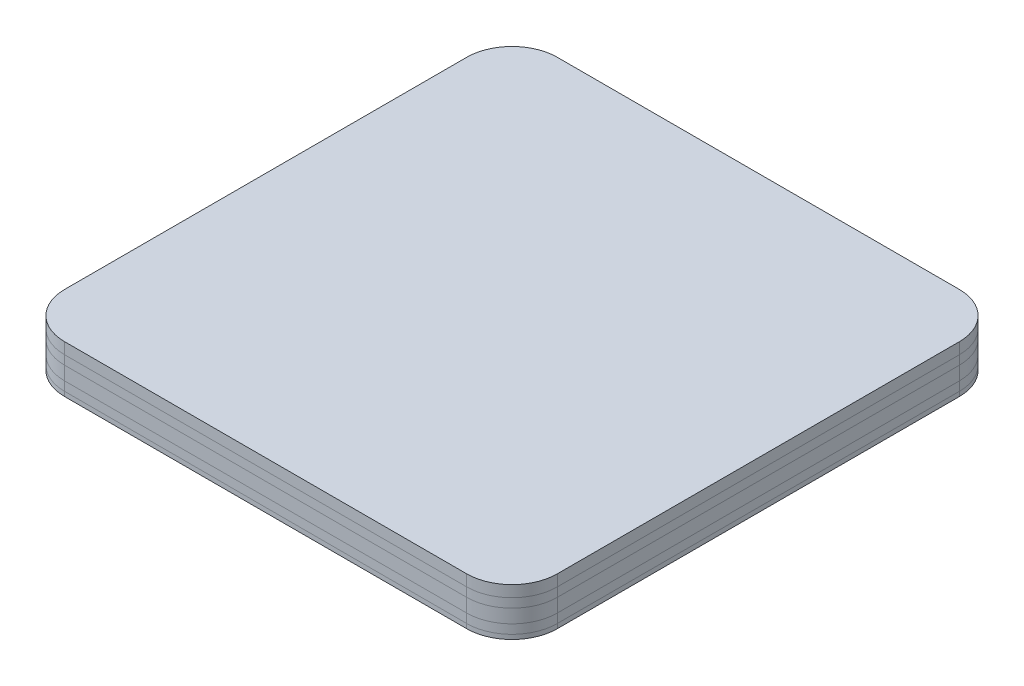
from build123d import *

# Parameters (mm, degrees)
BOSS_EXTRUDE1_DEPTH   = 0.1
BOSS_EXTRUDE2_START   = -0.1
BOSS_EXTRUDE2_DEPTH   = 1
BOSS_EXTRUDE3_DEPTH   = 4
BOSS_EXTRUDE3_2_DEPTH = 4
BOSS_EXTRUDE3_3_DEPTH = 4
BOSS_EXTRUDE3_4_DEPTH = 4
BOSS_EXTRUDE4_DEPTH   = 2
BOSS_EXTRUDE5_START   = 2
BOSS_EXTRUDE5_DEPTH   = 3
BOSS_EXTRUDE6_START   = 5
BOSS_EXTRUDE6_DEPTH   = 2
BOSS_EXTRUDE7_START   = 7
BOSS_EXTRUDE7_DEPTH   = 2.5


with BuildPart() as part:
    # Sketch2 → Boss-Extrude1 (new body)
    with BuildSketch(Plane(origin=(0, 0, 0), x_dir=(1, 0, 0), z_dir=(0, 1, 0))):
        with BuildLine():
            Line((44.4, 52.9), (-44.4, 52.9))
            ThreePointArc((-44.4, 52.9), (-50.41040764, 50.41040764), (-52.9, 44.4))
            Line((-52.9, 44.4), (-52.9, -44.4))
            ThreePointArc((-52.9, -44.4), (-50.41040764, -50.41040764), (-44.4, -52.9))
            Line((-44.4, -52.9), (44.4, -52.9))
            ThreePointArc((44.4, -52.9), (50.41040764, -50.41040764), (52.9, -44.4))
            Line((52.9, -44.4), (52.9, 44.4))
            ThreePointArc((52.9, 44.4), (50.41040764, 50.41040764), (44.4, 52.9))
        make_face()
        with BuildLine():
            Line((44.4, 51.9), (-44.4, 51.9))
            ThreePointArc((-44.4, 51.9), (-49.703300859, 49.703300859), (-51.9, 44.4))
            Line((-51.9, 44.4), (-51.9, -44.4))
            ThreePointArc((-51.9, -44.4), (-49.703300859, -49.703300859), (-44.4, -51.9))
            Line((-44.4, -51.9), (44.4, -51.9))
            ThreePointArc((44.4, -51.9), (49.703300859, -49.703300859), (51.9, -44.4))
            Line((51.9, -44.4), (51.9, 44.4))
            ThreePointArc((51.9, 44.4), (49.703300859, 49.703300859), (44.4, 51.9))
        make_face(mode=Mode.SUBTRACT)
    extrude(amount=-BOSS_EXTRUDE1_DEPTH)

    # Sketch1 → Boss-Extrude2 (add)
    with BuildSketch(Plane(origin=(0, 0, 0), x_dir=(1, 0, 0), z_dir=(0, 1, 0)).offset(BOSS_EXTRUDE2_START)):
        with BuildLine():
            Line((54.4, -44.4), (54.4, 44.4))
            ThreePointArc((54.4, 44.4), (51.471067812, 51.471067812), (44.4, 54.4))
            Line((44.4, 54.4), (-44.4, 54.4))
            ThreePointArc((-44.4, 54.4), (-51.471067812, 51.471067812), (-54.4, 44.4))
            Line((-54.4, 44.4), (-54.4, -44.4))
            ThreePointArc((-54.4, -44.4), (-51.471067812, -51.471067812), (-44.4, -54.4))
            Line((-44.4, -54.4), (44.4, -54.4))
            ThreePointArc((44.4, -54.4), (51.471067812, -51.471067812), (54.4, -44.4))
        make_face()
        with BuildLine():
            ThreePointArc((-44.4, 53.4), (-50.763961031, 50.763961031), (-53.4, 44.4))
            Line((-53.4, 44.4), (-53.4, -44.4))
            ThreePointArc((-53.4, -44.4), (-50.763961031, -50.763961031), (-44.4, -53.4))
            Line((-44.4, -53.4), (44.4, -53.4))
            ThreePointArc((44.4, -53.4), (50.763961031, -50.763961031), (53.4, -44.4))
            Line((53.4, -44.4), (53.4, 44.4))
            ThreePointArc((53.4, 44.4), (50.763961031, 50.763961031), (44.4, 53.4))
            Line((44.4, 53.4), (-44.4, 53.4))
        make_face(mode=Mode.SUBTRACT)
        with BuildLine():
            Line((-44.4, 53.4), (44.4, 53.4))
            ThreePointArc((44.4, 53.4), (50.763961031, 50.763961031), (53.4, 44.4))
            Line((53.4, 44.4), (53.4, -44.4))
            ThreePointArc((53.4, -44.4), (50.763961031, -50.763961031), (44.4, -53.4))
            Line((44.4, -53.4), (-44.4, -53.4))
            ThreePointArc((-44.4, -53.4), (-50.763961031, -50.763961031), (-53.4, -44.4))
            Line((-53.4, -44.4), (-53.4, 44.4))
            ThreePointArc((-53.4, 44.4), (-50.763961031, 50.763961031), (-44.4, 53.4))
        make_face()
    extrude(amount=BOSS_EXTRUDE2_DEPTH)


with BuildPart() as body_2:
    # Sketch3 → Boss-Extrude3 (new body)
    with BuildSketch(Plane.XZ.offset(0.1)):
        Polygon((-41.140539781, 40.026118716), (-37.997071749, 34.468775471), (-31.612537306, 34.41242702), (-28.371470895, 39.913421814), (-31.514938926, 45.470765058), (-37.899473369, 45.527113509), align=None)
    extrude(amount=BOSS_EXTRUDE3_DEPTH)


with BuildPart() as body_3:
    # Sketch3 → Boss-Extrude3 2 (new body)
    with BuildSketch(Plane.XZ.offset(0.1)):
        Polygon((23.419460219, 40.026118716), (26.56292825, 34.468775471), (32.947462693, 34.41242702), (36.188529105, 39.913421814), (33.045061073, 45.470765058), (26.66052663, 45.527113509), align=None)
    extrude(amount=BOSS_EXTRUDE3_2_DEPTH)


with BuildPart() as body_4:
    # Sketch3 → Boss-Extrude3 3 (new body)
    with BuildSketch(Plane.XZ.offset(0.1)):
        Polygon((34.321988768, -39.663881284), (37.4654568, -45.221224529), (43.849991243, -45.27757298), (47.091057654, -39.776578186), (43.947589623, -34.219234942), (37.56305518, -34.162886491), align=None)
    extrude(amount=BOSS_EXTRUDE3_3_DEPTH)


with BuildPart() as body_5:
    # Sketch3 → Boss-Extrude3 4 (new body)
    with BuildSketch(Plane.XZ.offset(0.1)):
        Polygon((-41.140539781, -33.533881284), (-37.997071749, -39.091224529), (-31.612537306, -39.14757298), (-28.371470895, -33.646578186), (-31.514938926, -28.089234942), (-37.899473369, -28.032886491), align=None)
    extrude(amount=BOSS_EXTRUDE3_4_DEPTH)


with BuildPart() as body_6:
    # Sketch4 → Boss-Extrude4 (new body)
    with BuildSketch(Plane(origin=(0, 0.9, 0), x_dir=(1, 0, 0), z_dir=(0, 1, 0))):
        with BuildLine():
            Line((54.4, -44.4), (54.4, 44.4))
            ThreePointArc((54.4, 44.4), (51.471067812, 51.471067812), (44.4, 54.4))
            Line((44.4, 54.4), (-44.4, 54.4))
            ThreePointArc((-44.4, 54.4), (-51.471067812, 51.471067812), (-54.4, 44.4))
            Line((-54.4, 44.4), (-54.4, -44.4))
            ThreePointArc((-54.4, -44.4), (-51.471067812, -51.471067812), (-44.4, -54.4))
            Line((-44.4, -54.4), (44.4, -54.4))
            ThreePointArc((44.4, -54.4), (51.471067812, -51.471067812), (54.4, -44.4))
        make_face()
    extrude(amount=BOSS_EXTRUDE4_DEPTH)


with BuildPart() as body_7:
    # Sketch4_2 → Boss-Extrude5 (new body)
    with BuildSketch(Plane(origin=(0, 0.9, 0), x_dir=(1, 0, 0), z_dir=(0, 1, 0)).offset(BOSS_EXTRUDE5_START)):
        with BuildLine():
            Line((54.4, -44.4), (54.4, 44.4))
            ThreePointArc((54.4, 44.4), (51.471067812, 51.471067812), (44.4, 54.4))
            Line((44.4, 54.4), (-44.4, 54.4))
            ThreePointArc((-44.4, 54.4), (-51.471067812, 51.471067812), (-54.4, 44.4))
            Line((-54.4, 44.4), (-54.4, -44.4))
            ThreePointArc((-54.4, -44.4), (-51.471067812, -51.471067812), (-44.4, -54.4))
            Line((-44.4, -54.4), (44.4, -54.4))
            ThreePointArc((44.4, -54.4), (51.471067812, -51.471067812), (54.4, -44.4))
        make_face()
    extrude(amount=BOSS_EXTRUDE5_DEPTH)


with BuildPart() as body_8:
    # Sketch4_3 → Boss-Extrude6 (new body)
    with BuildSketch(Plane(origin=(0, 0.9, 0), x_dir=(1, 0, 0), z_dir=(0, 1, 0)).offset(BOSS_EXTRUDE6_START)):
        with BuildLine():
            Line((54.4, -44.4), (54.4, 44.4))
            ThreePointArc((54.4, 44.4), (51.471067812, 51.471067812), (44.4, 54.4))
            Line((44.4, 54.4), (-44.4, 54.4))
            ThreePointArc((-44.4, 54.4), (-51.471067812, 51.471067812), (-54.4, 44.4))
            Line((-54.4, 44.4), (-54.4, -44.4))
            ThreePointArc((-54.4, -44.4), (-51.471067812, -51.471067812), (-44.4, -54.4))
            Line((-44.4, -54.4), (44.4, -54.4))
            ThreePointArc((44.4, -54.4), (51.471067812, -51.471067812), (54.4, -44.4))
        make_face()
    extrude(amount=BOSS_EXTRUDE6_DEPTH)


with BuildPart() as body_9:
    # Sketch4_4 → Boss-Extrude7 (new body)
    with BuildSketch(Plane(origin=(0, 0.9, 0), x_dir=(1, 0, 0), z_dir=(0, 1, 0)).offset(BOSS_EXTRUDE7_START)):
        with BuildLine():
            Line((54.4, -44.4), (54.4, 44.4))
            ThreePointArc((54.4, 44.4), (51.471067812, 51.471067812), (44.4, 54.4))
            Line((44.4, 54.4), (-44.4, 54.4))
            ThreePointArc((-44.4, 54.4), (-51.471067812, 51.471067812), (-54.4, 44.4))
            Line((-54.4, 44.4), (-54.4, -44.4))
            ThreePointArc((-54.4, -44.4), (-51.471067812, -51.471067812), (-44.4, -54.4))
            Line((-44.4, -54.4), (44.4, -54.4))
            ThreePointArc((44.4, -54.4), (51.471067812, -51.471067812), (54.4, -44.4))
        make_face()
    extrude(amount=BOSS_EXTRUDE7_DEPTH)


solid = Compound([part.part, body_2.part, body_3.part, body_4.part, body_5.part, body_6.part, body_7.part, body_8.part, body_9.part])
